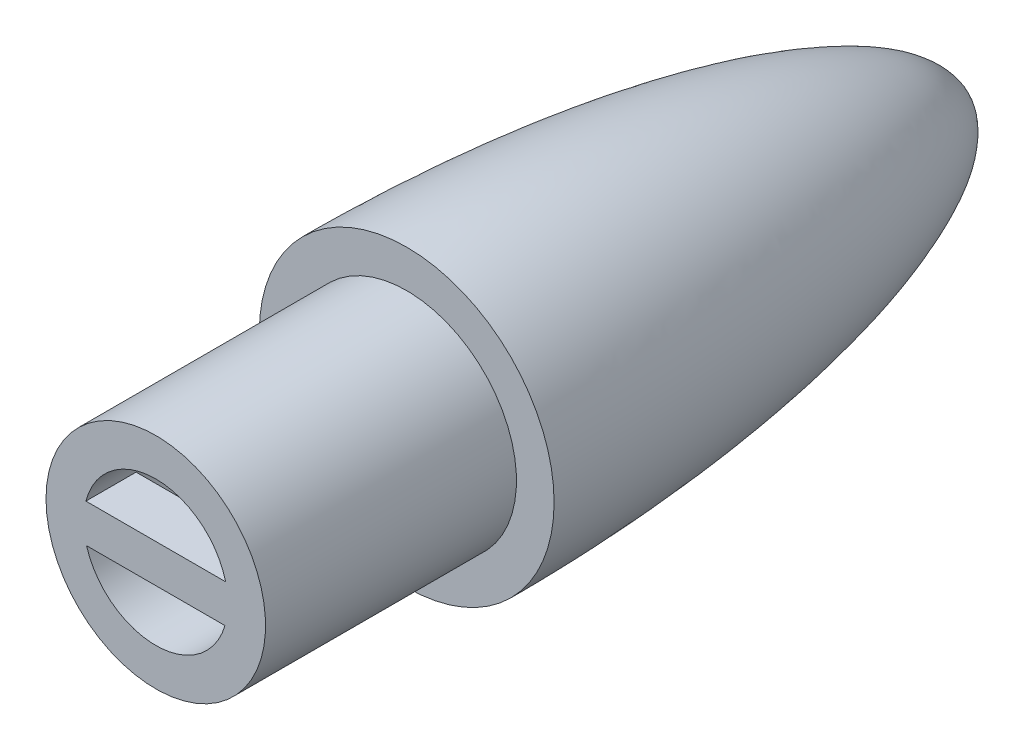
from build123d import *

# Parameters (mm, degrees)
SKETCH3_W           = 13.167666735
SKETCH3_H           = 3.048361989
BOSS_EXTRUDE7_DEPTH = 4


with BuildPart() as part:
    # Sketch1 → Revolve1 (revolve)
    with BuildSketch(Plane(origin=(0, 0, 0), x_dir=(1, 0, 0), z_dir=(0, 1, 0))):
        with BuildLine():
            Line((0, 11.422413793), (0, 8.922413793))
            Line((0, 8.922413793), (-6.034260666, -1.943584812))
            Line((-6.034260666, -1.943584812), (-8.75, -29.577586207))
            Line((-8.75, -29.577586207), (-5.75, -29.577586207))
            Line((-5.75, -29.577586207), (-5.75, -52.577586207))
            Line((-5.75, -52.577586207), (-8.75, -52.577586207))
            Line((-8.75, -52.577586207), (-8.75, -32.577586207))
            Line((-8.75, -32.577586207), (-11.75, -32.577586207))
            add(Edge.make_bspline(
                [(0, 11.422413793), (-1.278423588, 11.417026245), (-3.873144244, 9.558695327), (-5.944786969, 5.627242402), (-7.710873625, 0.905910608), (-8.885618359, -3.570284013), (-9.891395845, -8.594561629), (-10.670483225, -13.791762741), (-11.219012774, -19.122009095), (-11.530237696, -23.790668903), (-11.707521388, -28.093294524), (-11.749966177, -30.922446964), (-11.75, -32.577586207)],
                knots=[0, 0, 0, 0, 0.077095745, 0.191082865, 0.27602247, 0.396033744, 0.482752955, 0.599802605, 0.727919369, 0.821235279, 0.895416594, 1, 1, 1, 1], degree=3))
        make_face()
    revolve(axis=Axis((0, 0, -11.422413793), (0, 0, 1)))

    # Sketch3 → Boss-Extrude7 (add)
    with BuildSketch(Plane.XY.offset(52.577586207)):
        with Locations((0.047139619, -0.094279236)):
            Rectangle(SKETCH3_W, SKETCH3_H)
    extrude(amount=-BOSS_EXTRUDE7_DEPTH)


solid = part.part
